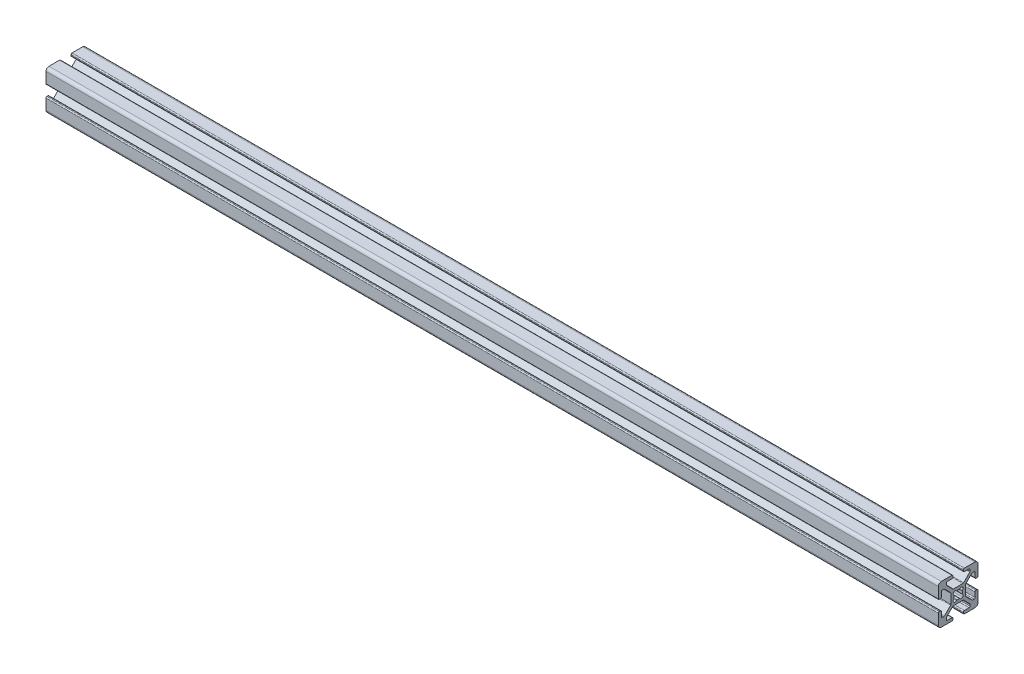
from build123d import *

# Parameters (mm, degrees)
F_20_SERIES_20_2020_1_DEPTH = 450


with BuildPart() as part:
    # Sketch11 → 20_series 20-2020(1) (new body)
    with BuildSketch(Plane.YZ):
        with BuildLine():
            Line((9.0094, 2.6289), (9.492, 2.6289))
            ThreePointArc((9.492, 2.6289), (9.851210245, 2.777689755), (10, 3.1369))
            Line((10, 3.1369), (10, 8.5014))
            ThreePointArc((10, 8.5014), (9.561070222, 9.561070222), (8.5014, 10))
            Line((8.5014, 10), (3.1369, 10))
            ThreePointArc((3.1369, 10), (2.777689755, 9.851210245), (2.6289, 9.492))
            Line((2.6289, 9.492), (2.6289, 9.0094))
            ThreePointArc((2.6289, 9.0094), (2.777689755, 8.650189755), (3.1369, 8.5014))
            Line((3.1369, 8.5014), (5.4864, 8.5014))
            ThreePointArc((5.4864, 8.5014), (5.845610245, 8.352610245), (5.9944, 7.9934))
            Line((5.9944, 7.9934), (5.9944, 7.264490712))
            ThreePointArc((5.9944, 7.264490712), (5.955730803, 7.070087528), (5.845610245, 6.905280467))
            Line((5.845610245, 6.905280467), (2.747686782, 3.807357004))
            ThreePointArc((2.747686782, 3.807357004), (2.582879721, 3.697236446), (2.388476537, 3.658567249))
            Line((2.388476537, 3.658567249), (-2.388476537, 3.658567249))
            ThreePointArc((-2.388476537, 3.658567249), (-2.582879721, 3.697236446), (-2.747686782, 3.807357004))
            Line((-2.747686782, 3.807357004), (-5.845610245, 6.905280467))
            ThreePointArc((-5.845610245, 6.905280467), (-5.955730803, 7.070087528), (-5.9944, 7.264490712))
            Line((-5.9944, 7.264490712), (-5.9944, 7.9934))
            ThreePointArc((-5.9944, 7.9934), (-5.845610245, 8.352610245), (-5.4864, 8.5014))
            Line((-5.4864, 8.5014), (-3.1369, 8.5014))
            ThreePointArc((-3.1369, 8.5014), (-2.777689755, 8.650189755), (-2.6289, 9.0094))
            Line((-2.6289, 9.0094), (-2.6289, 9.492))
            ThreePointArc((-2.6289, 9.492), (-2.777689755, 9.851210245), (-3.1369, 10))
            Line((-3.1369, 10), (-8.5014, 10))
            ThreePointArc((-8.5014, 10), (-9.561070222, 9.561070222), (-10, 8.5014))
            Line((-10, 8.5014), (-10, 3.1369))
            ThreePointArc((-10, 3.1369), (-9.851210245, 2.777689755), (-9.492, 2.6289))
            Line((-9.492, 2.6289), (-9.0094, 2.6289))
            ThreePointArc((-9.0094, 2.6289), (-8.650189755, 2.777689755), (-8.5014, 3.1369))
            Line((-8.5014, 3.1369), (-8.5014, 5.4864))
            ThreePointArc((-8.5014, 5.4864), (-8.352610245, 5.845610245), (-7.9934, 5.9944))
            Line((-7.9934, 5.9944), (-7.264490712, 5.9944))
            ThreePointArc((-7.264490712, 5.9944), (-7.070087528, 5.955730803), (-6.905280467, 5.845610245))
            Line((-6.905280467, 5.845610245), (-3.807357004, 2.747686782))
            ThreePointArc((-3.807357004, 2.747686782), (-3.697236446, 2.582879721), (-3.658567249, 2.388476537))
            Line((-3.658567249, 2.388476537), (-3.658567249, -2.388476537))
            ThreePointArc((-3.658567249, -2.388476537), (-3.697236446, -2.582879721), (-3.807357004, -2.747686782))
            Line((-3.807357004, -2.747686782), (-6.905280467, -5.845610245))
            ThreePointArc((-6.905280467, -5.845610245), (-7.070087528, -5.955730803), (-7.264490712, -5.9944))
            Line((-7.264490712, -5.9944), (-7.9934, -5.9944))
            ThreePointArc((-7.9934, -5.9944), (-8.352610245, -5.845610245), (-8.5014, -5.4864))
            Line((-8.5014, -5.4864), (-8.5014, -3.1369))
            ThreePointArc((-8.5014, -3.1369), (-8.650189755, -2.777689755), (-9.0094, -2.6289))
            Line((-9.0094, -2.6289), (-9.492, -2.6289))
            ThreePointArc((-9.492, -2.6289), (-9.851210245, -2.777689755), (-10, -3.1369))
            Line((-10, -3.1369), (-10, -8.5014))
            ThreePointArc((-10, -8.5014), (-9.561070222, -9.561070222), (-8.5014, -10))
            Line((-8.5014, -10), (-3.1369, -10))
            ThreePointArc((-3.1369, -10), (-2.777689755, -9.851210245), (-2.6289, -9.492))
            Line((-2.6289, -9.492), (-2.6289, -9.0094))
            ThreePointArc((-2.6289, -9.0094), (-2.777689755, -8.650189755), (-3.1369, -8.5014))
            Line((-3.1369, -8.5014), (-5.4864, -8.5014))
            ThreePointArc((-5.4864, -8.5014), (-5.845610245, -8.352610245), (-5.9944, -7.9934))
            Line((-5.9944, -7.9934), (-5.9944, -7.264490712))
            ThreePointArc((-5.9944, -7.264490712), (-5.955730803, -7.070087528), (-5.845610245, -6.905280467))
            Line((-5.845610245, -6.905280467), (-2.747686782, -3.807357004))
            ThreePointArc((-2.747686782, -3.807357004), (-2.582879721, -3.697236446), (-2.388476537, -3.658567249))
            Line((-2.388476537, -3.658567249), (2.388476537, -3.658567249))
            ThreePointArc((2.388476537, -3.658567249), (2.582879721, -3.697236446), (2.747686782, -3.807357004))
            Line((2.747686782, -3.807357004), (5.845610245, -6.905280467))
            ThreePointArc((5.845610245, -6.905280467), (5.955730803, -7.070087528), (5.9944, -7.264490712))
            Line((5.9944, -7.264490712), (5.9944, -7.9934))
            ThreePointArc((5.9944, -7.9934), (5.845610245, -8.352610245), (5.4864, -8.5014))
            Line((5.4864, -8.5014), (3.1369, -8.5014))
            ThreePointArc((3.1369, -8.5014), (2.777689755, -8.650189755), (2.6289, -9.0094))
            Line((2.6289, -9.0094), (2.6289, -9.492))
            ThreePointArc((2.6289, -9.492), (2.777689755, -9.851210245), (3.1369, -10))
            Line((3.1369, -10), (8.5014, -10))
            ThreePointArc((8.5014, -10), (9.561070222, -9.561070222), (10, -8.5014))
            Line((10, -8.5014), (10, -3.1369))
            ThreePointArc((10, -3.1369), (9.851210245, -2.777689755), (9.492, -2.6289))
            Line((9.492, -2.6289), (9.0094, -2.6289))
            ThreePointArc((9.0094, -2.6289), (8.650189755, -2.777689755), (8.5014, -3.1369))
            Line((8.5014, -3.1369), (8.5014, -5.4864))
            ThreePointArc((8.5014, -5.4864), (8.352610245, -5.845610245), (7.9934, -5.9944))
            Line((7.9934, -5.9944), (7.264490712, -5.9944))
            ThreePointArc((7.264490712, -5.9944), (7.070087528, -5.955730803), (6.905280467, -5.845610245))
            Line((6.905280467, -5.845610245), (3.807357004, -2.747686782))
            ThreePointArc((3.807357004, -2.747686782), (3.697236446, -2.582879721), (3.658567249, -2.388476537))
            Line((3.658567249, -2.388476537), (3.658567249, 2.388476537))
            ThreePointArc((3.658567249, 2.388476537), (3.697236446, 2.582879721), (3.807357004, 2.747686782))
            Line((3.807357004, 2.747686782), (6.905280467, 5.845610245))
            ThreePointArc((6.905280467, 5.845610245), (7.070087528, 5.955730803), (7.264490712, 5.9944))
            Line((7.264490712, 5.9944), (7.9934, 5.9944))
            ThreePointArc((7.9934, 5.9944), (8.352610245, 5.845610245), (8.5014, 5.4864))
            Line((8.5014, 5.4864), (8.5014, 3.1369))
            ThreePointArc((8.5014, 3.1369), (8.650189755, 2.777689755), (9.0094, 2.6289))
        make_face()
        with BuildLine():
            Line((-2.296558466, 2.121727546), (-2.121727546, 2.296558466))
            ThreePointArc((-2.121727546, 2.296558466), (-1.459775814, 2.520126613), (-0.880635441, 2.129282347))
            ThreePointArc((-0.880635441, 2.129282347), (-0.755121693, 2.019456424), (-0.588548999, 2.011151493))
            ThreePointArc((-0.588548999, 2.011151493), (0, 2.0955), (0.588548999, 2.011151493))
            ThreePointArc((0.588548999, 2.011151493), (0.755121693, 2.019456424), (0.880635441, 2.129282347))
            ThreePointArc((0.880635441, 2.129282347), (1.459775814, 2.520126613), (2.121727546, 2.296558466))
            Line((2.121727546, 2.296558466), (2.296558466, 2.121727546))
            ThreePointArc((2.296558466, 2.121727546), (2.520126613, 1.459775814), (2.129282347, 0.880635441))
            ThreePointArc((2.129282347, 0.880635441), (2.019456424, 0.755121693), (2.011151493, 0.588548999))
            ThreePointArc((2.011151493, 0.588548999), (2.0955, 0), (2.011151493, -0.588548999))
            ThreePointArc((2.011151493, -0.588548999), (2.019456424, -0.755121693), (2.129282347, -0.880635441))
            ThreePointArc((2.129282347, -0.880635441), (2.520126613, -1.459775814), (2.296558466, -2.121727546))
            Line((2.296558466, -2.121727546), (2.121727546, -2.296558466))
            ThreePointArc((2.121727546, -2.296558466), (1.459775814, -2.520126613), (0.880635441, -2.129282347))
            ThreePointArc((0.880635441, -2.129282347), (0.755121693, -2.019456424), (0.588548999, -2.011151493))
            ThreePointArc((0.588548999, -2.011151493), (0, -2.0955), (-0.588548999, -2.011151493))
            ThreePointArc((-0.588548999, -2.011151493), (-0.755121693, -2.019456424), (-0.880635441, -2.129282347))
            ThreePointArc((-0.880635441, -2.129282347), (-1.459775814, -2.520126613), (-2.121727546, -2.296558466))
            Line((-2.121727546, -2.296558466), (-2.296558466, -2.121727546))
            ThreePointArc((-2.296558466, -2.121727546), (-2.520126613, -1.459775814), (-2.129282347, -0.880635441))
            ThreePointArc((-2.129282347, -0.880635441), (-2.019456424, -0.755121693), (-2.011151493, -0.588548999))
            ThreePointArc((-2.011151493, -0.588548999), (-2.0955, 0), (-2.011151493, 0.588548999))
            ThreePointArc((-2.011151493, 0.588548999), (-2.019456424, 0.755121693), (-2.129282347, 0.880635441))
            ThreePointArc((-2.129282347, 0.880635441), (-2.520126613, 1.459775814), (-2.296558466, 2.121727546))
        make_face(mode=Mode.SUBTRACT)
    extrude(amount=F_20_SERIES_20_2020_1_DEPTH)


solid = part.part
